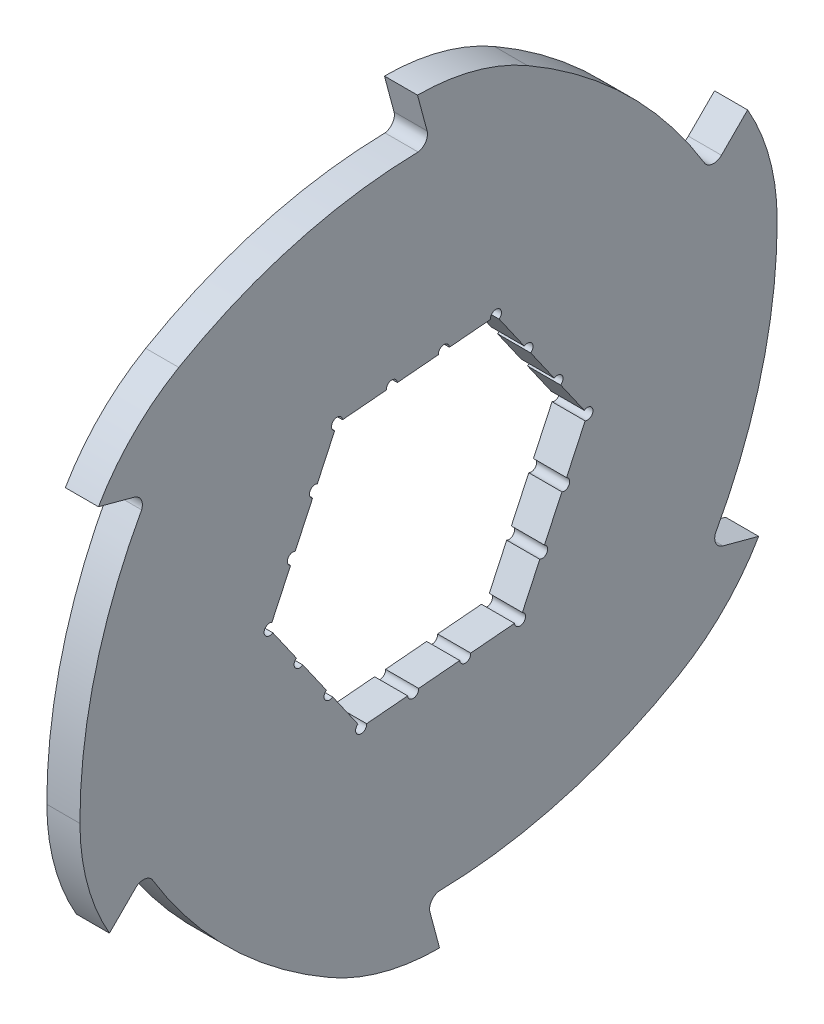
from build123d import *

# Parameters (mm, degrees)
SKETCH1_R                = 59
EXTRUDE1_DEPTH           = 3
EXTRUDE2_DEPTH           = 3
CIRPATTERN1_COUNT        = 6
F_2_0_2_DIAMETER_HOLE1_D = 2
F_2_0_2_DIAMETER_HOLE3_D = 2
F_2_0_2_DIAMETER_HOLE4_D = 2
CIRPATTERN2_COUNT        = 6
CIRPATTERN3_COUNT        = 6


with BuildPart() as part:
    # Sketch1 → Extrude1 (new, symmetric)
    with BuildSketch(Plane(origin=(0, 0, 0), x_dir=(0, 0, -1), z_dir=(1, 0, 0))):
        Circle(SKETCH1_R)
        Polygon((28.815179183, 2.521001516), (12.224338236, 26.215177945), (-16.590840947, 23.694176429), (-28.815179183, -2.521001516), (-12.224338236, -26.215177945), (16.590840947, -23.694176429), align=None, mode=Mode.SUBTRACT)
    extrude(amount=EXTRUDE1_DEPTH, both=True)

    # Sketch2 → Extrude2 (add, symmetric)
    with BuildSketch(Plane(origin=(0, 0, 0), x_dir=(0, 0, -1), z_dir=(1, 0, 0))):
        with BuildLine():
            Line((-2, 67.961805723), (-0.262709442, 61.478149092))
            ThreePointArc((-0.262709442, 61.478149092), (-0.58620663, 59.77173183), (-2.122608272, 58.961805723))
            ThreePointArc((-2.122608272, 58.961805723), (28.679663449, 51.560419941), (51.21368579, 29.294340542))
            ThreePointArc((51.21368579, 29.294340542), (36.791707484, 48.186627241), (17.927108603, 62.644803614))
            ThreePointArc((17.927108603, 62.644803614), (8.312130826, 66.609702921), (-2, 67.961805723))
        make_face()
    extrude2 = extrude(amount=EXTRUDE2_DEPTH, both=True)

    # CirPattern1: Extrude2 ×6 about axis
    cirpattern1_axis = Axis((0, 0, 0), (1, 0, 0))
    for i in range(1, CIRPATTERN1_COUNT):
        add(extrude2.rotate(cirpattern1_axis, i * 360 / CIRPATTERN1_COUNT))

    # Ø2.0 (2) Diameter Hole1 (through all)
    with Locations(Plane(origin=(3, 0, 0), x_dir=(0, 0, -1), z_dir=(1, 0, 0))):
        with Locations((12.224338236, 26.215177945), (28.815179183, 2.521001516), (16.590840947, -23.694176429), (-12.224338236, -26.215177945), (-28.815179183, -2.521001516), (-16.590840947, 23.694176429)):
            Hole(F_2_0_2_DIAMETER_HOLE1_D / 2)

    # Ø2.0 (2) Diameter Hole3 (through all)
    with Locations(Plane(origin=(3, 0, 0), x_dir=(0, 0, -1), z_dir=(1, 0, 0))):
        with Locations((17.945810697, 18.044068454)):
            f_2_0_2_diameter_hole3 = Hole(F_2_0_2_DIAMETER_HOLE3_D / 2)

    # Ø2.0 (2) Diameter Hole4 (through all)
    with Locations(Plane(origin=(3, 0, 0), x_dir=(0, 0, -1), z_dir=(1, 0, 0))):
        with Locations((23.38049494, 10.282534985)):
            f_2_0_2_diameter_hole4 = Hole(F_2_0_2_DIAMETER_HOLE4_D / 2)

    # CirPattern2: Ø2.0 (2) Diameter Hole3 ×6 about axis
    cirpattern2_axis = Axis((0, 0, 0), (1, 0, 0))
    for i in range(1, CIRPATTERN2_COUNT):
        add(f_2_0_2_diameter_hole3.rotate(cirpattern2_axis, i * 360 / CIRPATTERN2_COUNT), mode=Mode.SUBTRACT)

    # CirPattern3: Ø2.0 (2) Diameter Hole4 ×6 about axis
    cirpattern3_axis = Axis((0, 0, 0), (1, 0, 0))
    for i in range(1, CIRPATTERN3_COUNT):
        add(f_2_0_2_diameter_hole4.rotate(cirpattern3_axis, i * 360 / CIRPATTERN3_COUNT), mode=Mode.SUBTRACT)


solid = part.part
